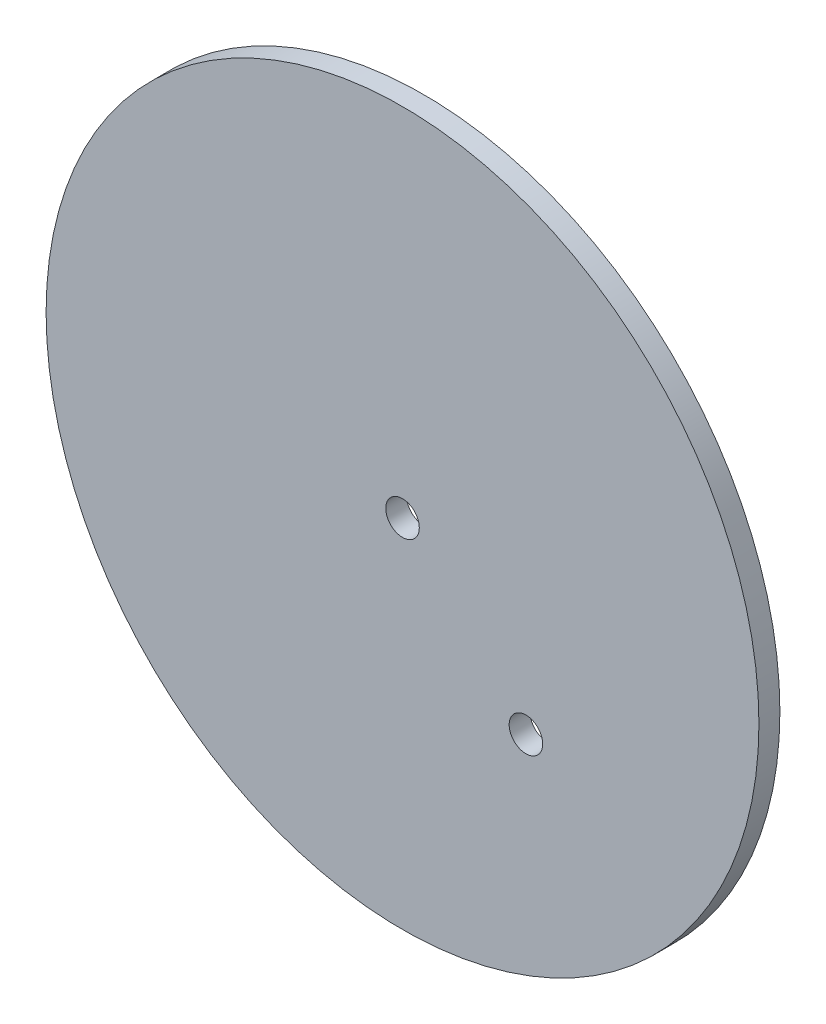
from build123d import *

# Parameters (mm, degrees)
BOSS_EXTRUDE1_DEPTH      = 1.25
BOSS_EXTRUDE1_DEPTH_BACK = 1.25
SKETCH1_R                = 42.5
SKETCH1_R_2              = 2


with BuildPart() as part:
    # Sketch1 → Boss-Extrude1 (new, two sides: drawn at the far end of the back side and taken through both)
    with BuildSketch(Plane.XY.offset(-BOSS_EXTRUDE1_DEPTH_BACK)):
        Circle(SKETCH1_R)
        with Locations((14.715815051, -14.981481481)):
            Circle(SKETCH1_R_2, mode=Mode.SUBTRACT)
        Circle(SKETCH1_R_2, mode=Mode.SUBTRACT)
    extrude(amount=BOSS_EXTRUDE1_DEPTH + BOSS_EXTRUDE1_DEPTH_BACK)


solid = part.part
